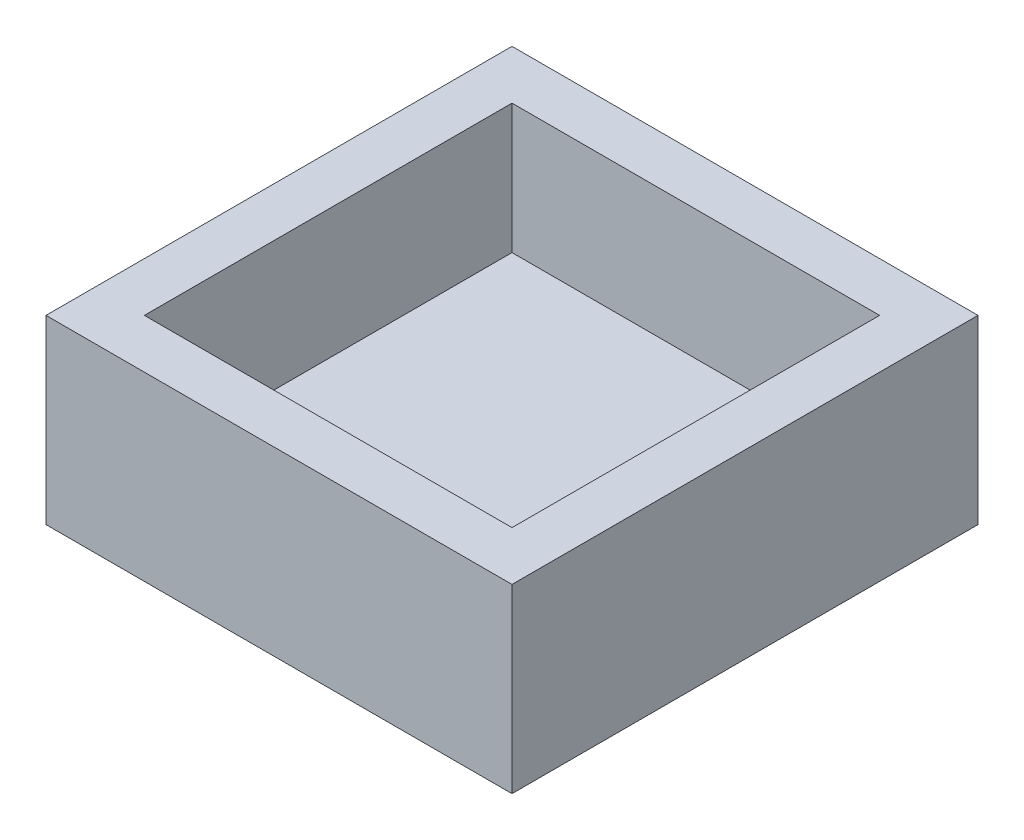
from build123d import *

# Parameters (mm, degrees)
SKETCH1_W           = 18
SKETCH1_H           = 18
BOSS_EXTRUDE1_DEPTH = 7
SKETCH2_W           = 14.2
SKETCH2_H           = 14.2
CUT_EXTRUDE1_DEPTH  = 5


with BuildPart() as part:
    # Sketch1 → Boss-Extrude1 (new body)
    with BuildSketch(Plane(origin=(0, 0, 0), x_dir=(1, 0, 0), z_dir=(0, 1, 0))):
        Rectangle(SKETCH1_W, SKETCH1_H)
    extrude(amount=BOSS_EXTRUDE1_DEPTH)

    # Sketch2 → Cut-Extrude1 (cut)
    with BuildSketch(Plane(origin=(0, 7, 0), x_dir=(1, 0, 0), z_dir=(0, 1, 0))):
        Rectangle(SKETCH2_W, SKETCH2_H)
    extrude(amount=-CUT_EXTRUDE1_DEPTH, mode=Mode.SUBTRACT)


solid = part.part
